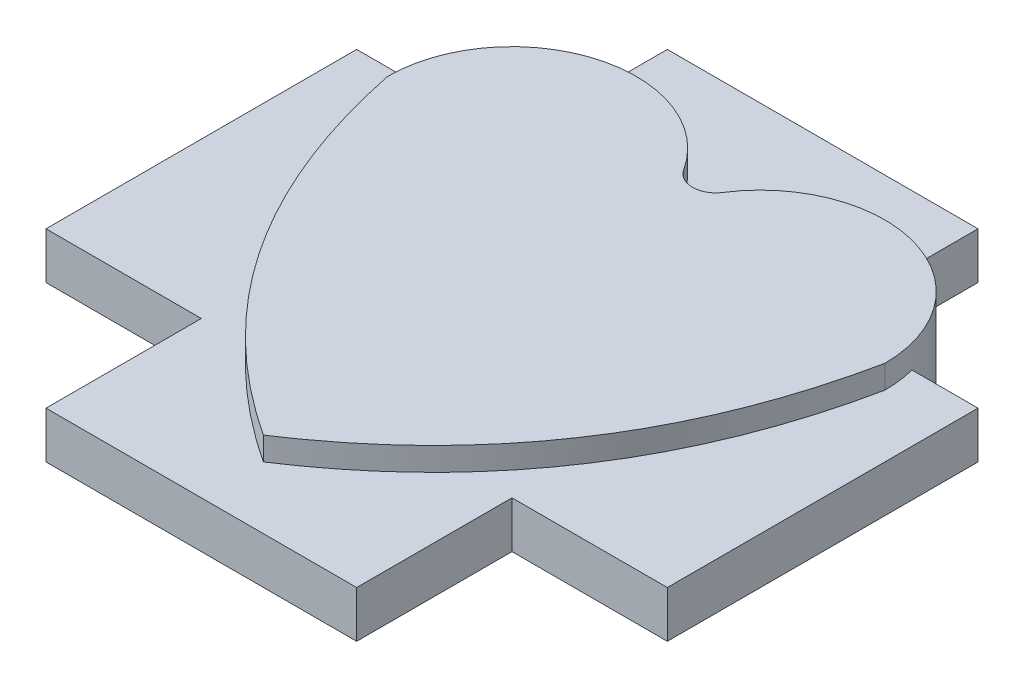
from build123d import *

# Parameters (mm, degrees)
BOSS_EXTRUDE3_DEPTH      = 3
SKETCH2_W                = 8.5
SKETCH2_H                = 10
SKETCH2_W_2              = 10
SKETCH2_H_2              = 20
BOSS_EXTRUDE4_DEPTH      = 0.75
BOSS_EXTRUDE4_DEPTH_BACK = 0.75


with BuildPart() as part:
    # Sketch1 → Boss-Extrude3 (new body)
    with BuildSketch(Plane(origin=(0, 0, 0), x_dir=(1, 0, 0), z_dir=(0, 1, 0))):
        with BuildLine():
            ThreePointArc((-0.631578947, 6.157252793), (-5.123902974, 7.83885948), (-8, 4))
            add(Edge.make_bspline(
                [(-8, 4), (-6.403336947, -3.811544104), (0, -8)],
                knots=[0, 0, 0, 1, 1, 1], degree=2))
            add(Edge.make_bspline(
                [(8, 4), (6.403336947, -3.811544104), (0, -8)],
                knots=[0, 0, 0, 1, 1, 1], degree=2))
            ThreePointArc((8, 4), (5.123902974, 7.83885948), (0.631578947, 6.157252793))
            ThreePointArc((0.631578947, 6.157252793), (0, 5.811737691), (-0.631578947, 6.157252793))
        make_face()
    extrude(amount=BOSS_EXTRUDE3_DEPTH)

    # Sketch2 → Boss-Extrude4 (add, two sides)
    with BuildSketch(Plane(origin=(0, 1.5, 0), x_dir=(1, 0, 0), z_dir=(0, 1, 0))) as boss_extrude4_sk:
        with Locations((-5.75, 0)):
            Rectangle(SKETCH2_W, SKETCH2_H)
        with Locations((5.75, 0)):
            Rectangle(SKETCH2_W, SKETCH2_H)
        Rectangle(SKETCH2_W_2, SKETCH2_H_2)
        with BuildLine():
            ThreePointArc((8, 3.999999998), (5.123902975, 7.838859479), (0.631578947, 6.157252793))
            ThreePointArc((0.631578947, 6.157252793), (0, 5.811737691), (-0.631578947, 6.157252793))
            ThreePointArc((-0.631578947, 6.157252793), (-5.123902974, 7.83885948), (-8, 4))
            add(Edge.make_bspline(
                [(-8, 4), (-6.403336946, -3.811544103), (3e-09, -7.999999998)],
                knots=[0, 0, 0, 1, 1, 1], degree=2))
            add(Edge.make_bspline(
                [(3e-09, -7.999999998), (6.403336946, -3.811544103), (8, 3.999999998)],
                knots=[0, 0, 0, 1, 1, 1], degree=2))
        make_face()
    extrude(amount=BOSS_EXTRUDE4_DEPTH)
    extrude(boss_extrude4_sk.sketch, amount=-BOSS_EXTRUDE4_DEPTH_BACK)


solid = part.part
